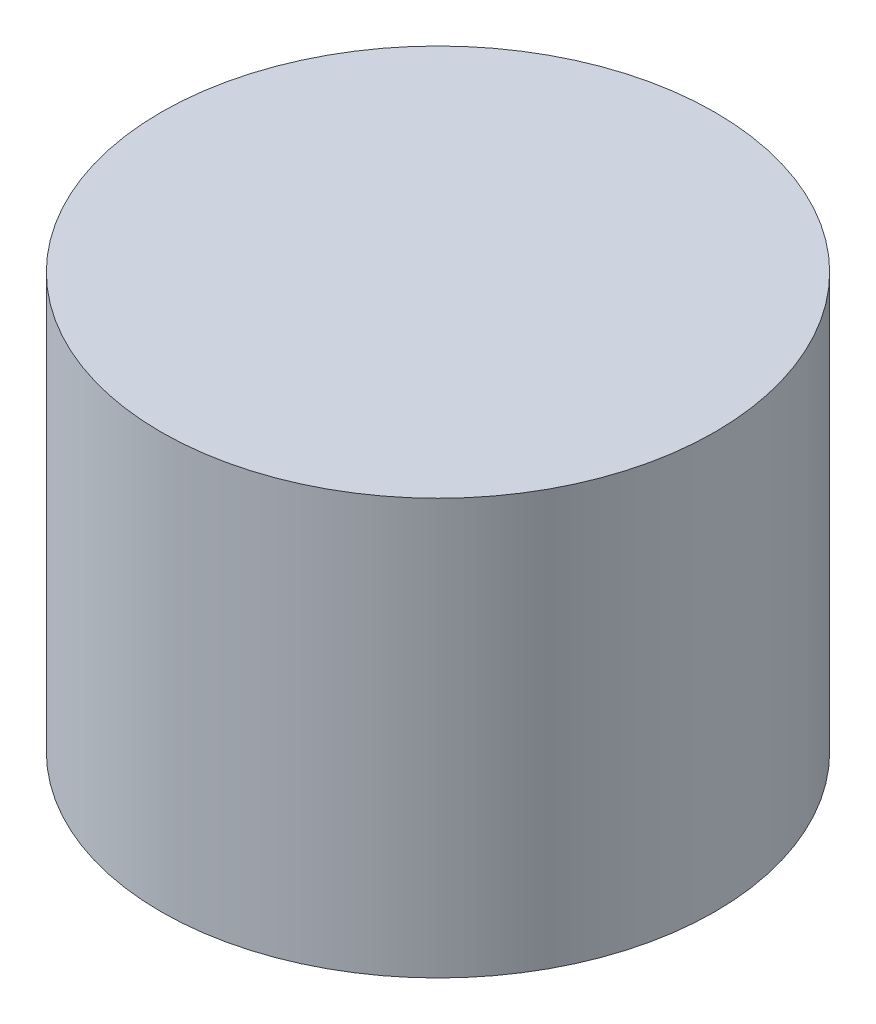
from build123d import *

# Parameters (mm, degrees)
SKETCH2_R           = 25.4
BOSS_EXTRUDE1_DEPTH = 38.1


with BuildPart() as part:
    # Sketch2 → Boss-Extrude1 (new body)
    with BuildSketch(Plane(origin=(0, 0, 0), x_dir=(1, 0, 0), z_dir=(0, 1, 0))):
        Circle(SKETCH2_R)
    extrude(amount=BOSS_EXTRUDE1_DEPTH)


solid = part.part
